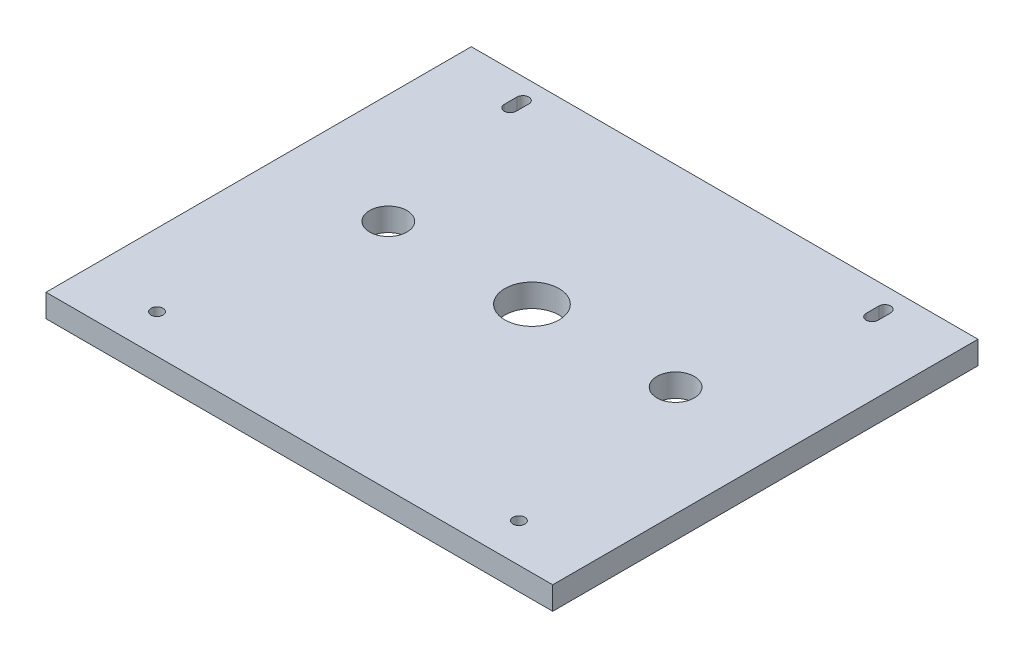
from build123d import *

# Parameters (mm, degrees)
SKETCH1_W           = 140
SKETCH1_H           = 117.505
BOSS_EXTRUDE1_DEPTH = 6.35
SKETCH2_R           = 1.65
SKETCH2_R_2         = 7.5
SKETCH2_R_3         = 5.16
CUT_EXTRUDE1_DEPTH  = 7.35


with BuildPart() as part:
    # Sketch1 → Boss-Extrude1 (new body)
    with BuildSketch(Plane(origin=(0, 0, 0), x_dir=(1, 0, 0), z_dir=(0, 1, 0))):
        with Locations((70, 58.7525)):
            Rectangle(SKETCH1_W, SKETCH1_H)
    extrude(amount=BOSS_EXTRUDE1_DEPTH)

    # Sketch2 → Cut-Extrude1 (cut, through all)
    with BuildSketch(Plane(origin=(0, 6.35, 0), x_dir=(1, 0, 0), z_dir=(0, 1, 0))):
        with Locations((20, 10.675)):
            Circle(SKETCH2_R)
        with Locations((70, 64.265)):
            Circle(SKETCH2_R_2)
        with Locations((30.3125, 64.265)):
            Circle(SKETCH2_R_3)
        with Locations((120, 10.675)):
            Circle(SKETCH2_R)
        with Locations((109.6875, 64.265)):
            Circle(SKETCH2_R_3)
        with BuildLine():
            Line((18.35, 108.255), (18.35, 111.755))
            ThreePointArc((18.35, 111.755), (20, 113.405), (21.65, 111.755))
            Line((21.65, 111.755), (21.65, 108.255))
            ThreePointArc((21.65, 108.255), (20, 106.605), (18.35, 108.255))
        make_face()
        with BuildLine():
            Line((121.65, 108.255), (121.65, 111.755))
            ThreePointArc((121.65, 111.755), (120, 113.405), (118.35, 111.755))
            Line((118.35, 111.755), (118.35, 108.255))
            ThreePointArc((118.35, 108.255), (120, 106.605), (121.65, 108.255))
        make_face()
    extrude(amount=-CUT_EXTRUDE1_DEPTH, mode=Mode.SUBTRACT)


solid = part.part
